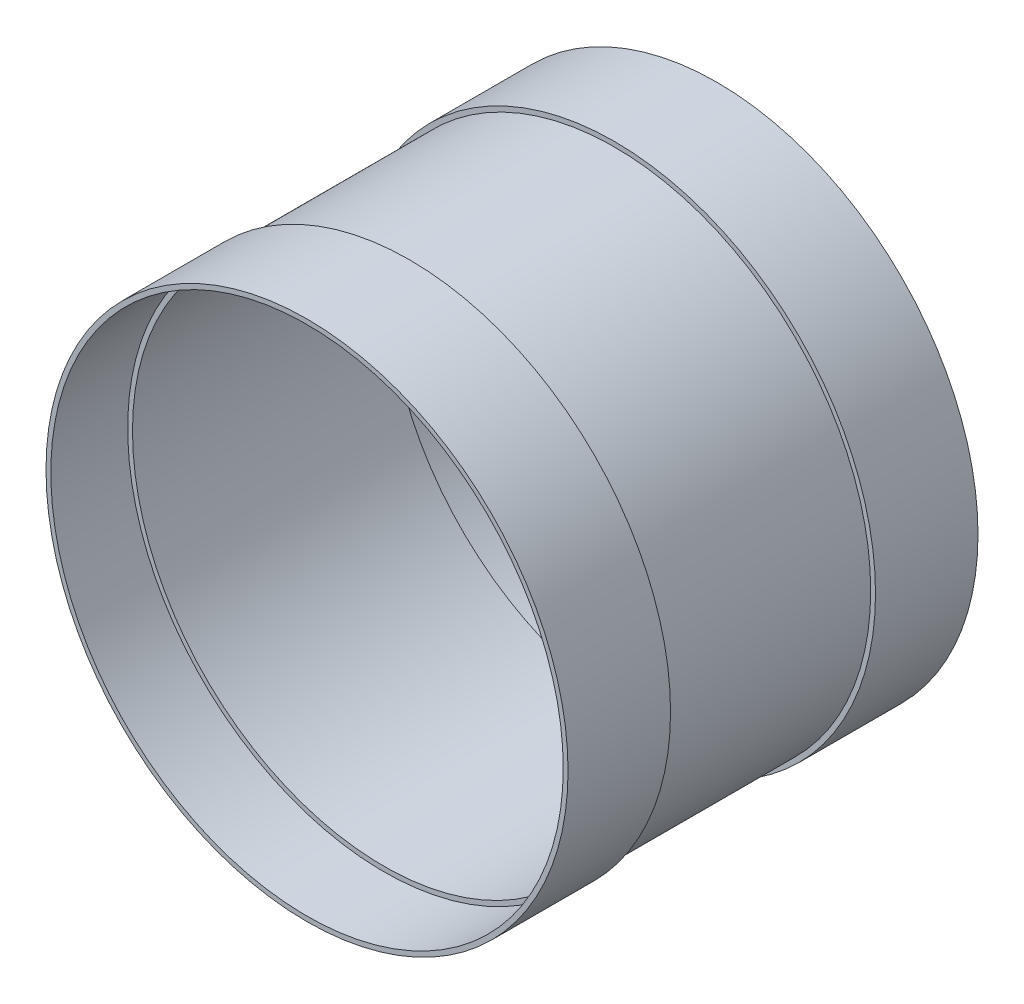
from build123d import *

# Parameters (mm, degrees)
SKETCH2_W = 101.6
SKETCH2_H = 4.7625
SKETCH3_W = 254
SKETCH3_H = 4.7625


with BuildPart() as part:
    # Sketch2 → Revolve1 (revolve)
    with BuildSketch(Plane(origin=(0, 0, 0), x_dir=(0, 0, -1), z_dir=(1, 0, 0)), mode=Mode.PRIVATE) as revolve1_sk:
        with Locations((-152.4, 256.38125)):
            Rectangle(SKETCH2_W, SKETCH2_H)
        with Locations((152.4, 256.38125)):
            Rectangle(SKETCH2_W, SKETCH2_H)
    revolve(revolve1_sk.sketch.rotate(Axis((0, 0, 62.594581749), (0, 0, -1)), 90), axis=Axis((0, 0, 62.594581749), (0, 0, -1)))  # turned: the seam where the file's is


with BuildPart() as body_2:
    # Sketch3 → Revolve2 (revolve)
    with BuildSketch(Plane(origin=(0, 0, 0), x_dir=(0, 0, -1), z_dir=(1, 0, 0)), mode=Mode.PRIVATE) as revolve2_sk:
        with Locations((0, 251.61875)):
            Rectangle(SKETCH3_W, SKETCH3_H)
    revolve(revolve2_sk.sketch.rotate(Axis((0, 0, 0), (0, 0, -1)), 90), axis=Axis((0, 0, 0), (0, 0, -1)))  # turned: the seam where the file's is


solid = Compound([part.part, body_2.part])
